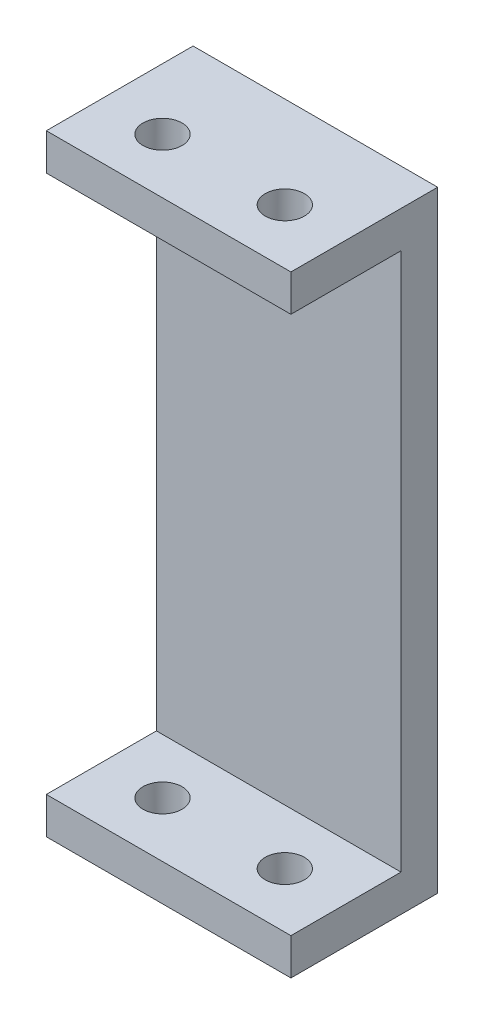
from build123d import *

# Parameters (mm, degrees)
SKETCH_1_W          = 20
SKETCH_1_H          = 50
EXTRUDE_1_DEPTH     = 12
SKETCH_2_W          = 20
SKETCH_2_H          = 44
CUT_EXTRUDE_1_DEPTH = 9
SKETCH_3_R          = 1.6
CUT_EXTRUDE_2_DEPTH = 51


with BuildPart() as part:
    # 草图1 → 凸台-拉伸1 (new body)
    with BuildSketch(Plane.XY):
        with Locations((-5.803858521, -0.908360129)):
            Rectangle(SKETCH_1_W, SKETCH_1_H)
    extrude(amount=EXTRUDE_1_DEPTH)

    # 草图2 → 切除-拉伸1 (cut)
    with BuildSketch(Plane.XY.offset(12)):
        with Locations((-5.803858521, -0.908360129)):
            Rectangle(SKETCH_2_W, SKETCH_2_H)
    extrude(amount=-CUT_EXTRUDE_1_DEPTH, mode=Mode.SUBTRACT)

    # 草图3 → 切除-拉伸2 (cut, through all)
    with BuildSketch(Plane(origin=(0, 24.091639871, 0), x_dir=(1, 0, 0), z_dir=(0, 1, 0))):
        with Locations((-10.803858521, -7.5)):
            Circle(SKETCH_3_R)
        with Locations((-0.803858521, -7.5)):
            Circle(SKETCH_3_R)
    extrude(amount=-CUT_EXTRUDE_2_DEPTH, mode=Mode.SUBTRACT)


solid = part.part
